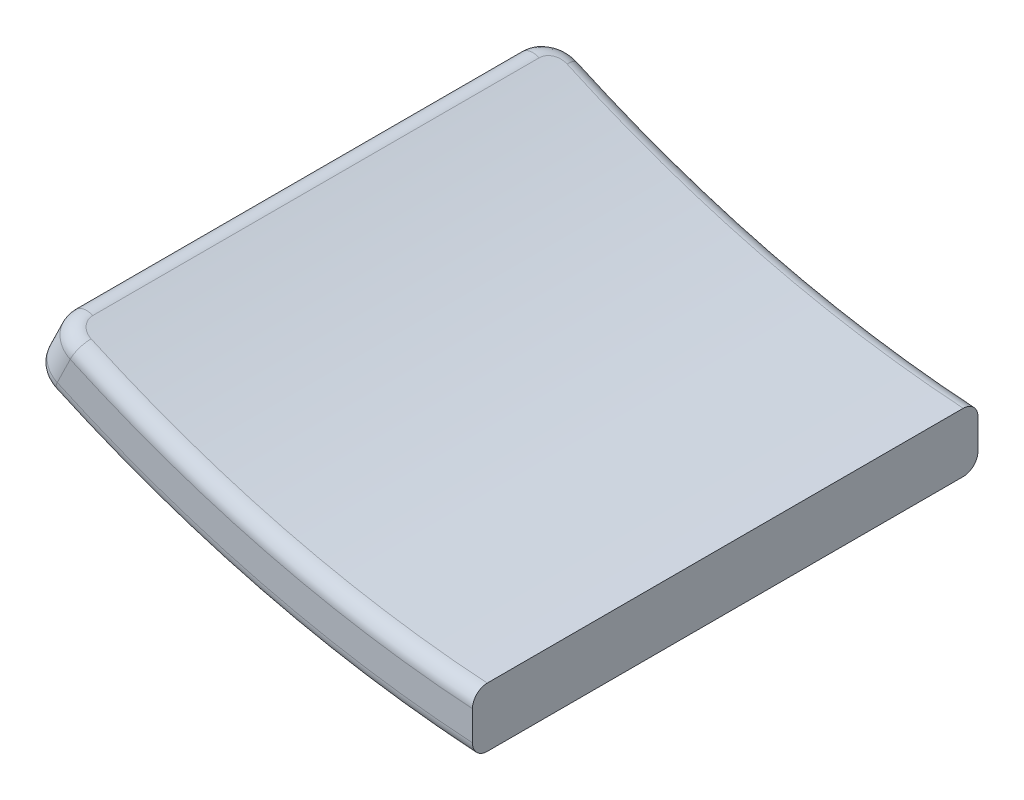
from build123d import *

# Parameters (mm, degrees)
BOSS_EXTRUDE1_DEPTH = 434.6
FILLET1_R           = 25.4
FILLET2_R           = 12.7


with BuildPart() as part:
    # Sketch1 → Boss-Extrude1 (new body)
    with BuildSketch(Plane.XY):
        with BuildLine():
            Line((-50.8, 241.861797239), (-50.8, 190.955582052))
            ThreePointArc((-50.8, 190.955582052), (-248.54641158, 223.033274611), (-436.283591965, 292.943021812))
            Line((-436.283591965, 292.943021812), (-413.99080623, 338.590274786))
            ThreePointArc((-413.99080623, 338.590274786), (-237.101828879, 272.554605518), (-50.8, 241.861797239))
        make_face()
    extrude(amount=-BOSS_EXTRUDE1_DEPTH)

    # Fillet1
    fillet1_edges = [part.edges().sort_by_distance(p)[0] for p in [
        (-425.137199097, 315.766648299, -434.6),
        (-425.137199097, 315.766648299, 0),
    ]]
    fillet(fillet1_edges, radius=FILLET1_R)

    # Fillet2
    fillet2_edges = [part.edges().sort_by_distance(p)[0] for p in [
        (-236.247784218, 219.860784348, -434.6),
        (-236.247784218, 219.860784348, 0),
        (-436.283591965, 292.943021812, -217.3),
        (-429.586107636, 289.70220341, -427.161351846),
        (-429.586107636, 289.70220341, -7.438648154),
        (-413.99080623, 338.590274786, -217.3),
        (-224.807276662, 269.365840187, -434.6),
        (-407.292621944, 335.350680861, -427.161443503),
        (-407.292621944, 335.350680861, -7.438556497),
        (-224.807276662, 269.365840187, 0),
    ]]
    fillet(fillet2_edges, radius=FILLET2_R)


solid = part.part
